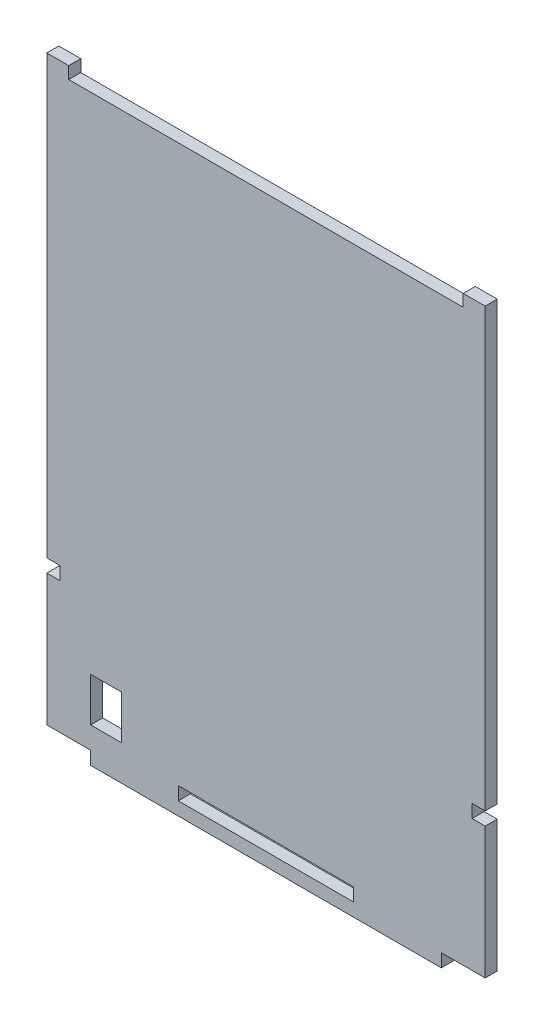
from build123d import *

# Parameters (mm, degrees)
SKETCH_1_W          = 5
SKETCH_1_H          = 2.75
EXTRUDE_1_DEPTH     = 2.75
SKETCH_2_W          = 7
SKETCH_2_H          = 10
CUT_EXTRUDE_1_DEPTH = 10


with BuildPart() as part:
    # 草图1 → 凸台-拉伸1 (new body)
    with BuildSketch(Plane.XY):
        Polygon((95, 100), (100, 100), (100, 102.75), (95, 102.75), (95, 102.449578136), align=None)
        Polygon((3, 3), (3, 0), (97, 0), (97, 3), (100, 3), (100, 100), (95, 100), (5, 100), (0, 100), (0, 3), align=None)
        with Locations((2.5, 101.375)):
            Rectangle(SKETCH_1_W, SKETCH_1_H)
        Polygon((0, 0), (0, -30), (10, -30), (30, -30), (30, -27), (50, -27), (70, -27), (70, -30), (90, -30), (100, -30), (100, 0), (97, 0), (3, 0), align=None)
        Polygon((30, -30), (10, -30), (10, -33), (90, -33), (90, -30), (70, -30), (50, -30), align=None)
    extrude(amount=EXTRUDE_1_DEPTH)

    # 草图2 → 切除-拉伸1 (cut)
    with BuildSketch(Plane.XY.offset(2.75)):
        with Locations((13.5, -20)):
            Rectangle(SKETCH_2_W, SKETCH_2_H)
    extrude(amount=-CUT_EXTRUDE_1_DEPTH, mode=Mode.SUBTRACT)


solid = part.part
